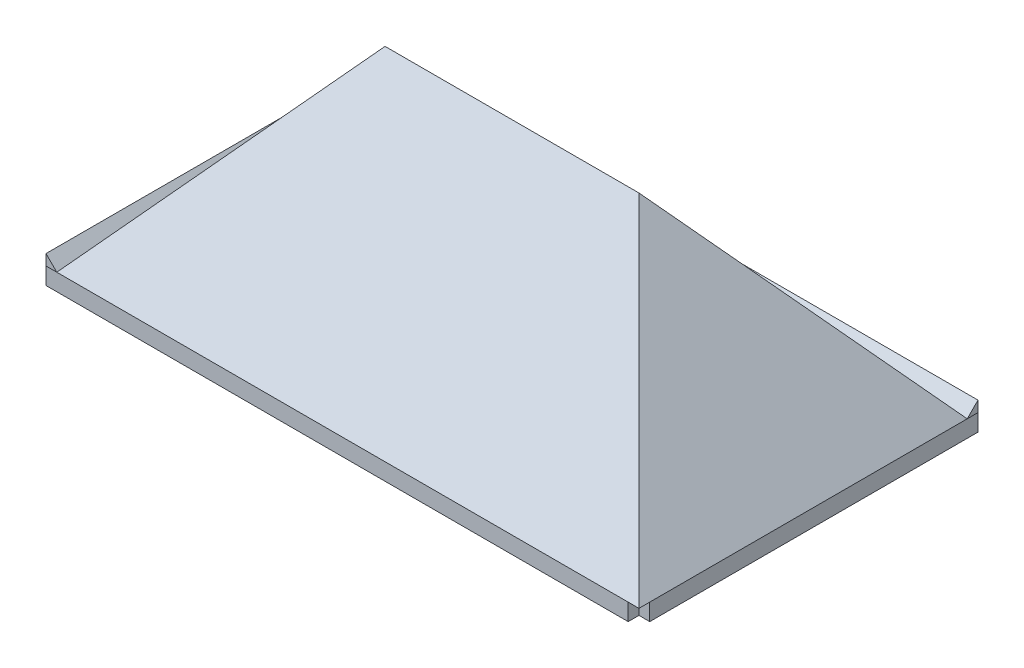
from build123d import *

# Parameters (mm, degrees)
BOSS_EXTRUDE2_DEPTH      = 120
CUT_EXTRUDE3_DEPTH       = 150
SHELL3_T                 = -4
BOSS_EXTRUDE3_DEPTH      = 107
BOSS_EXTRUDE3_DEPTH_BACK = 107
BOSS_EXTRUDE5_DEPTH      = 107
BOSS_EXTRUDE5_DEPTH_BACK = 107
BOSS_EXTRUDE6_DEPTH      = 122
BOSS_EXTRUDE6_DEPTH_BACK = 2
BOSS_EXTRUDE7_DEPTH      = 122
BOSS_EXTRUDE7_DEPTH_BACK = 2
SKETCH12_W               = 3.825022673
SKETCH12_H               = 3.825022673
CUT_EXTRUDE11_DEPTH      = 6


with BuildPart() as part:
    # Sketch1 → Boss-Extrude2 (new body)
    with BuildSketch(Plane.XY):
        Polygon((0, 125.134127222), (105, 0), (0, 0), (-105, 0), align=None)
    extrude(amount=BOSS_EXTRUDE2_DEPTH)

    # Sketch4 → Cut-Extrude3 (cut, symmetric)
    with BuildSketch(Plane(origin=(0, 0, 0), x_dir=(0, 0, -1), z_dir=(1, 0, 0))):
        Polygon((-120, 0), (-60, 71.505215556), (0, 0), (0, 125.134127222), (-120, 125.134127222), align=None)
    extrude(amount=CUT_EXTRUDE3_DEPTH, both=True, mode=Mode.SUBTRACT)

    # Shell3
    shell3_openings = [part.faces().sort_by_distance(p)[0] for p in [
        (0, 0, 60),
    ]]
    offset(amount=SHELL3_T, openings=shell3_openings, kind=Kind.INTERSECTION)

    # Sketch5 → Boss-Extrude3 (add, two sides)
    with BuildSketch(Plane(origin=(0, 0, 0), x_dir=(0, 0, -1), z_dir=(1, 0, 0))) as boss_extrude3_sk:
        Polygon((2, 6), (-4, 0), (2, 0), align=None)
    extrude(amount=BOSS_EXTRUDE3_DEPTH)
    extrude(boss_extrude3_sk.sketch, amount=-BOSS_EXTRUDE3_DEPTH_BACK)

    # Sketch9 → Boss-Extrude5 (add, two sides)
    with BuildSketch(Plane(origin=(0, 0, 0), x_dir=(0, 0, -1), z_dir=(1, 0, 0))) as boss_extrude5_sk:
        Polygon((-116, 0), (-122, 6), (-122, 0), align=None)
    extrude(amount=BOSS_EXTRUDE5_DEPTH)
    extrude(boss_extrude5_sk.sketch, amount=-BOSS_EXTRUDE5_DEPTH_BACK)

    # Sketch10 → Boss-Extrude6 (add, two sides)
    with BuildSketch(Plane.XY) as boss_extrude6_sk:
        Polygon((107, 6), (101, 0), (107, 0), align=None)
    extrude(amount=BOSS_EXTRUDE6_DEPTH)
    extrude(boss_extrude6_sk.sketch, amount=-BOSS_EXTRUDE6_DEPTH_BACK)

    # Sketch11 → Boss-Extrude7 (add, two sides)
    with BuildSketch(Plane.XY) as boss_extrude7_sk:
        Polygon((-107, 6), (-101, 0), (-107, 0), align=None)
    extrude(amount=BOSS_EXTRUDE7_DEPTH)
    extrude(boss_extrude7_sk.sketch, amount=-BOSS_EXTRUDE7_DEPTH_BACK)

    # Sketch12 → Cut-Extrude11 (cut)
    with BuildSketch(Plane(origin=(0, 0, 0), x_dir=(1, 0, 0), z_dir=(0, 1, 0))):
        with Locations((-105.087488664, 0.087488663)):
            Rectangle(SKETCH12_W, SKETCH12_H)
        with Locations((-105.087488664, -120.087488664)):
            Rectangle(SKETCH12_W, SKETCH12_H)
        with Locations((105.087488664, -120.087488664)):
            Rectangle(SKETCH12_W, SKETCH12_H)
        with Locations((105.087488664, 0.087488663)):
            Rectangle(SKETCH12_W, SKETCH12_H)
    extrude(amount=CUT_EXTRUDE11_DEPTH, mode=Mode.SUBTRACT)


solid = part.part
